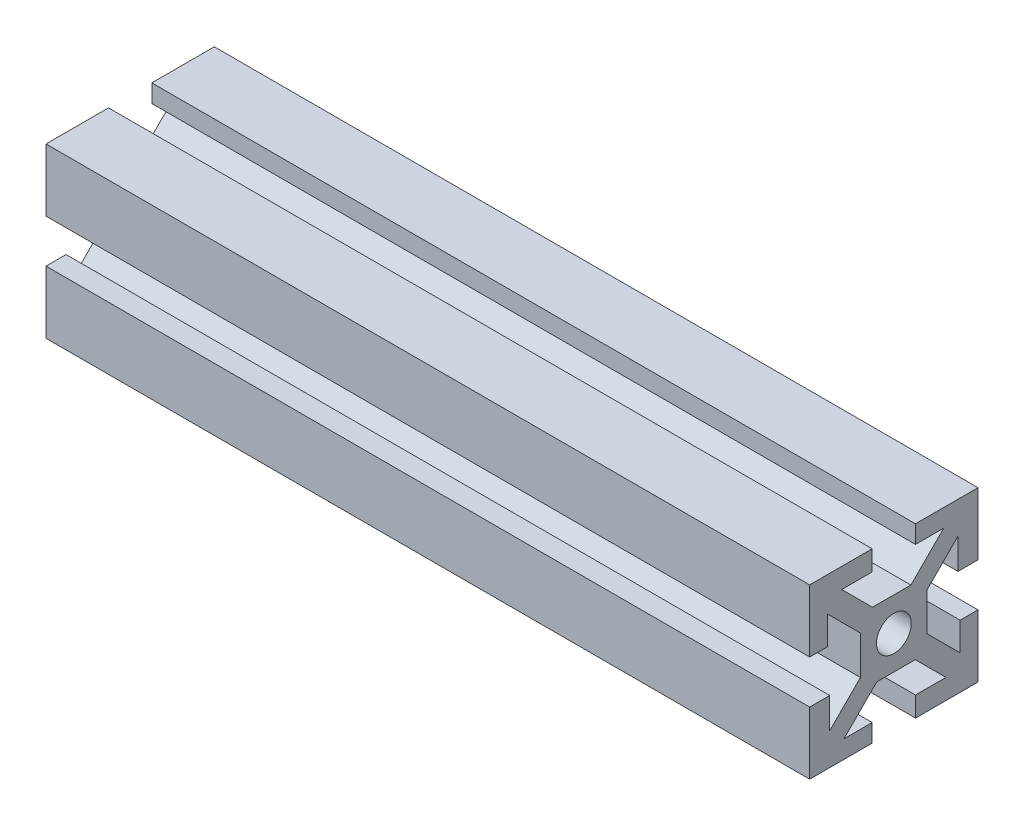
from build123d import *

# Parameters (mm, degrees)
SKETCH1_R           = 2.605
BOSS_EXTRUDE1_DEPTH = 114.3
CIRPATTERN1_COUNT   = 4


with BuildPart() as part:
    # Sketch1 → Boss-Extrude1 (new body)
    with BuildSketch(Plane(origin=(0, 0, 0), x_dir=(0, 0, -1), z_dir=(1, 0, 0))):
        Polygon((5, -5), (5, 3.203948776), (9.596194078, 7.800142853), (9.596194078, 3.24), (12.596194078, 3.24), (12.596194078, 12.596194078), (3.24, 12.596194078), (3.24, 9.921463197), (7.474873734, 9.921463197), (2.553410537, 5), (-5, 5), (-5, -5), align=None)
        Circle(SKETCH1_R, mode=Mode.SUBTRACT)
    boss_extrude1 = extrude(amount=BOSS_EXTRUDE1_DEPTH)

    # CirPattern1: Boss-Extrude1 ×4 about axis
    cirpattern1_axis = Axis((0, 0, 0), (1, 0, 0))
    for i in range(1, CIRPATTERN1_COUNT):
        add(boss_extrude1.rotate(cirpattern1_axis, i * 360 / CIRPATTERN1_COUNT))


solid = part.part
